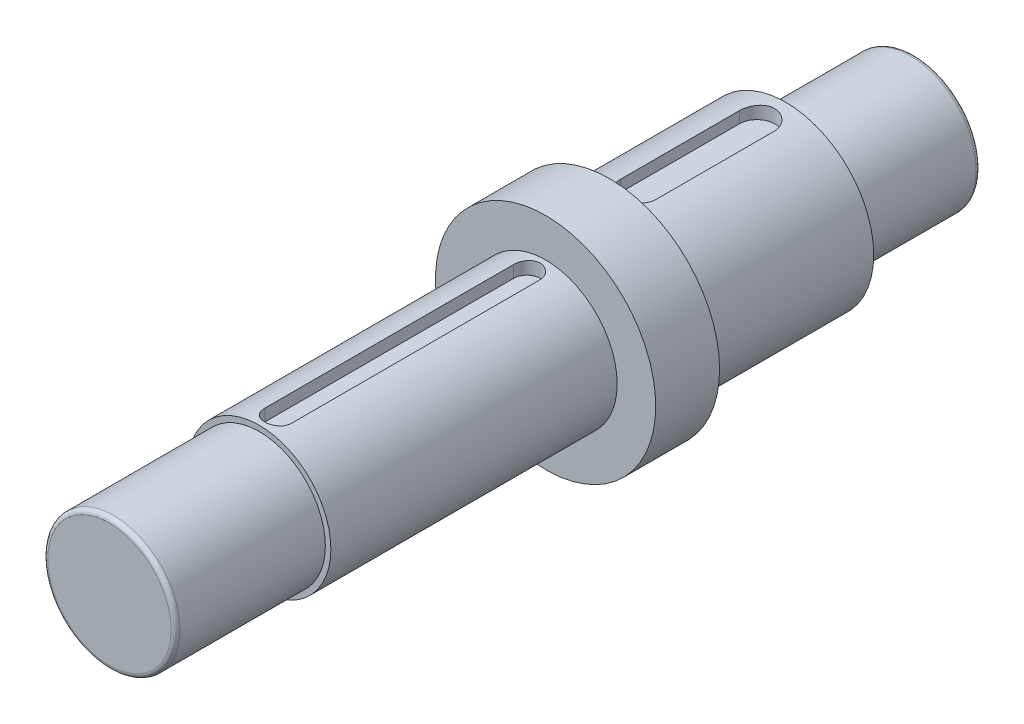
from build123d import *

# Parameters (mm, degrees)
FILLET1_R          = 2
CUT_EXTRUDE1_START = 34
CUT_EXTRUDE1_DEPTH = 10
CUT_EXTRUDE2_START = 26.5
CUT_EXTRUDE2_DEPTH = 10


with BuildPart() as part:
    # Sketch1 → Revolve1 (revolve)
    with BuildSketch(Plane(origin=(0, 0, 0), x_dir=(0, 0, -1), z_dir=(1, 0, 0))):
        Polygon((0, 0), (-365.5, 0), (-365.5, 30), (-297.5, 30), (-297.5, 32.5), (-167.5, 32.5), (-167.5, 50), (-138.5, 50), (-138.5, 40), (-58.5, 40), (-58.5, 30), (0, 30), align=None)
    revolve(axis=Axis((0, 0, 0), (0, 0, -1)))

    # Fillet1
    fillet1_edges = [part.edges().sort_by_distance(p)[0] for p in [
        (0, -30, 365.5),
        (0, -30, 0),
    ]]
    fillet(fillet1_edges, radius=FILLET1_R)

    # Sketch2 → Cut-Extrude1 (cut)
    with BuildSketch(Plane(origin=(0, 0, 0), x_dir=(1, 0, 0), z_dir=(0, 1, 0)).offset(CUT_EXTRUDE1_START)):
        with BuildLine():
            Line((8, -71.5), (8, -125.5))
            ThreePointArc((8, -125.5), (0, -133.5), (-8, -125.5))
            Line((-8, -125.5), (-8, -71.5))
            ThreePointArc((-8, -71.5), (0, -63.5), (8, -71.5))
        make_face()
    extrude(amount=CUT_EXTRUDE1_DEPTH, mode=Mode.SUBTRACT)

    # Sketch3 → Cut-Extrude2 (cut)
    with BuildSketch(Plane(origin=(0, 0, 0), x_dir=(1, 0, 0), z_dir=(0, 1, 0)).offset(CUT_EXTRUDE2_START)):
        with BuildLine():
            Line((6, -176), (6, -289))
            ThreePointArc((6, -289), (0, -295), (-6, -289))
            Line((-6, -289), (-6, -176))
            ThreePointArc((-6, -176), (0, -170), (6, -176))
        make_face()
    extrude(amount=CUT_EXTRUDE2_DEPTH, mode=Mode.SUBTRACT)


solid = part.part
